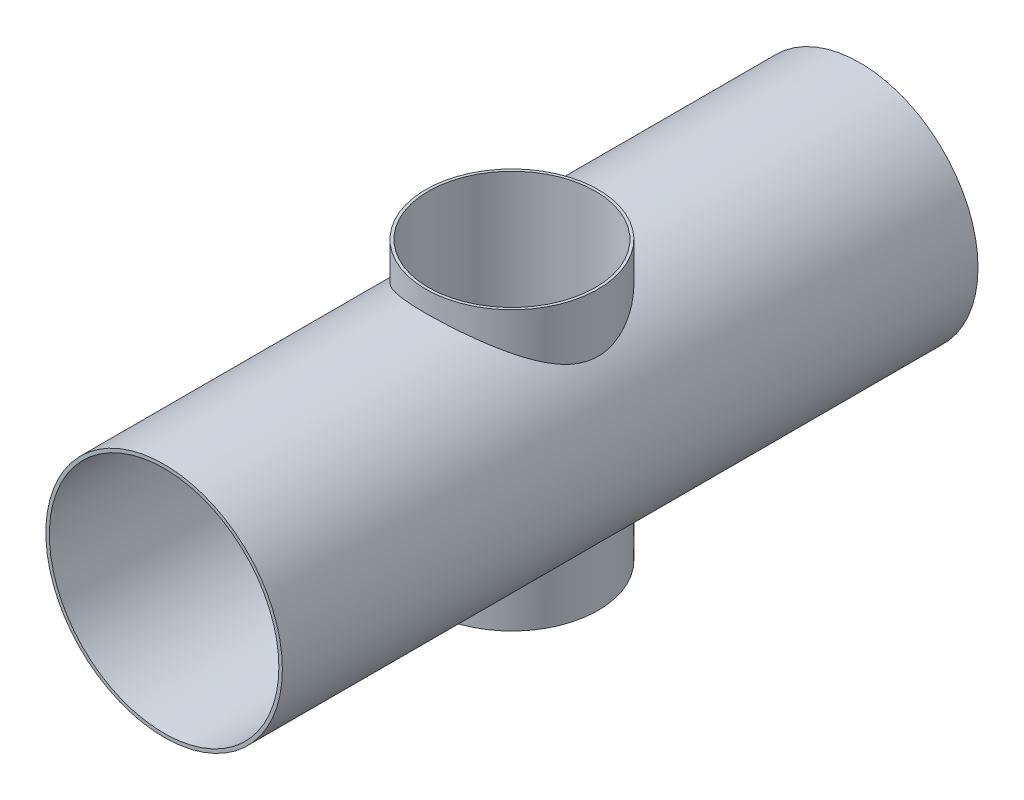
from build123d import *

# Parameters (mm, degrees)
SKETCH1_R                            = 85
SKETCH1_R_2                          = 82.5
BOSS_EXTRUDE1_DEPTH                  = 500
BOSS_EXTRUDE2_REACH                  = 516.247
BOSS_EXTRUDE2_END_RADIUS             = 82.5
SKETCH4_W                            = 120
SKETCH4_H                            = 2
BOSS_EXTRUDE2_DIRECTION_2_REACH      = 516.247
BOSS_EXTRUDE2_DIRECTION_2_END_RADIUS = 82.5
BOSS_EXTRUDE3_DEPTH                  = 100
BOSS_EXTRUDE3_DEPTH_BACK             = 100
SKETCH5_R                            = 62
SKETCH5_R_2                          = 60
CUT_EXTRUDE1_DEPTH                   = 100
CUT_EXTRUDE1_DEPTH_BACK              = 100
SKETCH6_R                            = 60


with BuildPart() as part:
    # Sketch1 → Boss-Extrude1 (new body)
    with BuildSketch(Plane.XY):
        Circle(SKETCH1_R)
        Circle(SKETCH1_R_2, mode=Mode.SUBTRACT)
    extrude(amount=BOSS_EXTRUDE1_DEPTH)

    # Boss-Extrude2: up to this cylinder (the profile starts inside it)
    boss_extrude2_end = Plane(origin=(0, 0, 60), z_dir=(0, 0, -1)) * Cylinder(BOSS_EXTRUDE2_END_RADIUS, 1198.494, mode=Mode.PRIVATE)
    # Sketch4 → Boss-Extrude2 (add, up to the surface)
    with BuildSketch(Plane(origin=(0, 0, 0), x_dir=(0, 0, -1), z_dir=(1, 0, 0)), mode=Mode.PRIVATE) as boss_extrude2_sk1:
        with Locations((-60, -38.109770221)):
            Rectangle(SKETCH4_W, SKETCH4_H)
    boss_extrude2_tool1 = extrude(boss_extrude2_sk1.sketch, amount=BOSS_EXTRUDE2_REACH, mode=Mode.PRIVATE) & boss_extrude2_end
    add(boss_extrude2_tool1.solids().sort_by_distance((0, -38.10977, 60))[0])

    # Boss-Extrude2 direction 2: up to this cylinder (the profile starts inside it)
    boss_extrude2_direction_2_end = Plane(origin=(0, 0, 60), z_dir=(0, 0, -1)) * Cylinder(BOSS_EXTRUDE2_DIRECTION_2_END_RADIUS, 1198.494, mode=Mode.PRIVATE)
    # Sketch4 → Boss-Extrude2 direction 2 (add, up to the surface)
    with BuildSketch(Plane(origin=(0, 0, 0), x_dir=(0, 0, -1), z_dir=(1, 0, 0)), mode=Mode.PRIVATE) as boss_extrude2_direction_2_sk1:
        with Locations((-60, -38.109770221)):
            Rectangle(SKETCH4_W, SKETCH4_H)
    boss_extrude2_direction_2_tool1 = extrude(boss_extrude2_direction_2_sk1.sketch, amount=-BOSS_EXTRUDE2_DIRECTION_2_REACH, mode=Mode.PRIVATE) & boss_extrude2_direction_2_end
    add(boss_extrude2_direction_2_tool1.solids().sort_by_distance((0, -38.10977, 60))[0])

    # Sketch5 → Boss-Extrude3 (add, two sides: drawn at the far end of the back side and taken through both)
    with BuildSketch(Plane(origin=(0, 0, 0), x_dir=(1, 0, 0), z_dir=(0, 1, 0)).offset(-BOSS_EXTRUDE3_DEPTH_BACK)):
        with Locations((0, -250)):
            Circle(SKETCH5_R)
        with Locations((0, -250)):
            Circle(SKETCH5_R_2, mode=Mode.SUBTRACT)
    extrude(amount=BOSS_EXTRUDE3_DEPTH + BOSS_EXTRUDE3_DEPTH_BACK)

    # Sketch6 → Cut-Extrude1 (cut, two sides: drawn at the far end of the back side and taken through both)
    with BuildSketch(Plane(origin=(0, 0, 0), x_dir=(1, 0, 0), z_dir=(0, 1, 0)).offset(-CUT_EXTRUDE1_DEPTH_BACK)):
        with Locations((0, -250)):
            Circle(SKETCH6_R)
    extrude(amount=CUT_EXTRUDE1_DEPTH + CUT_EXTRUDE1_DEPTH_BACK, mode=Mode.SUBTRACT)


solid = part.part
